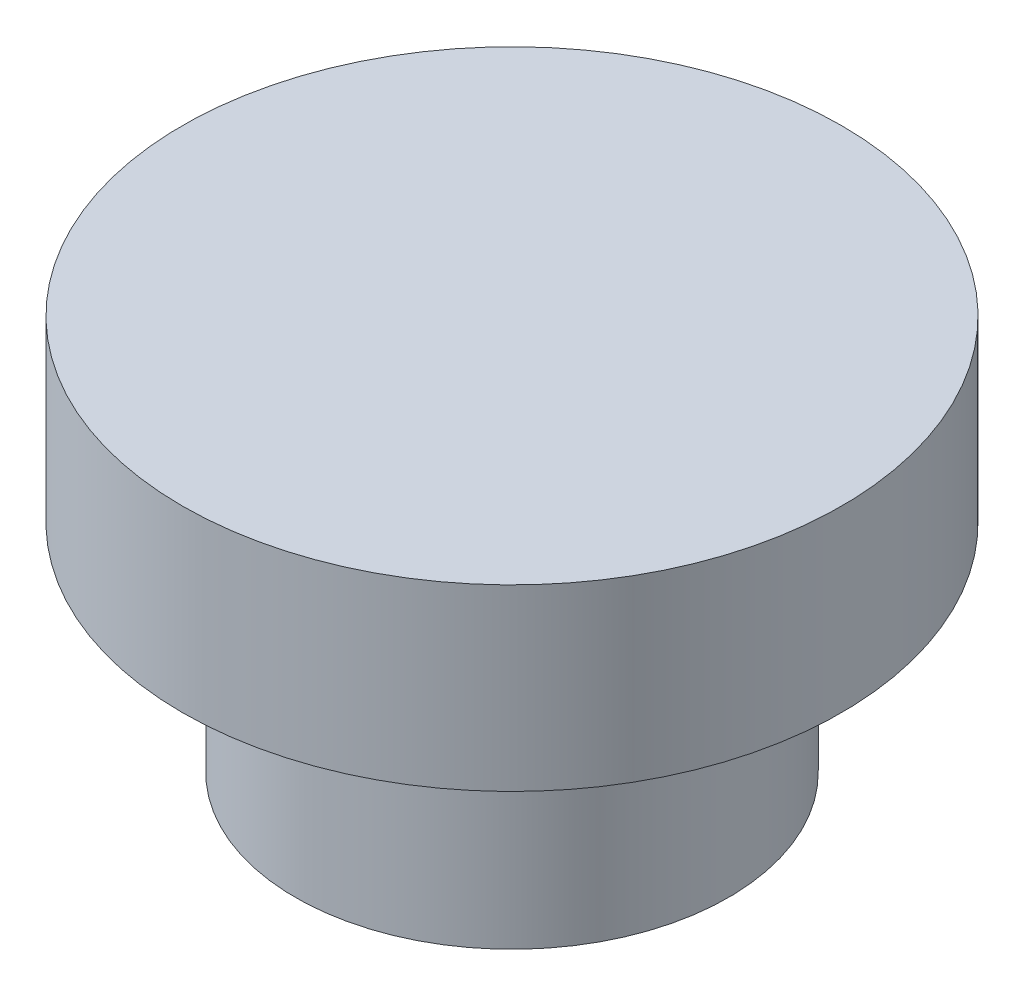
from build123d import *


with BuildPart() as part:
    # Sketch1 → Revolve1 (revolve)
    with BuildSketch(Plane.XY):
        Polygon((0, 0), (0, 5.334), (4.445, 5.334), (4.445, 2.921), (2.921, 2.921), (2.921, 0), align=None)
    revolve(axis=Axis((0, 0, 0), (0, 1, 0)))


solid = part.part
